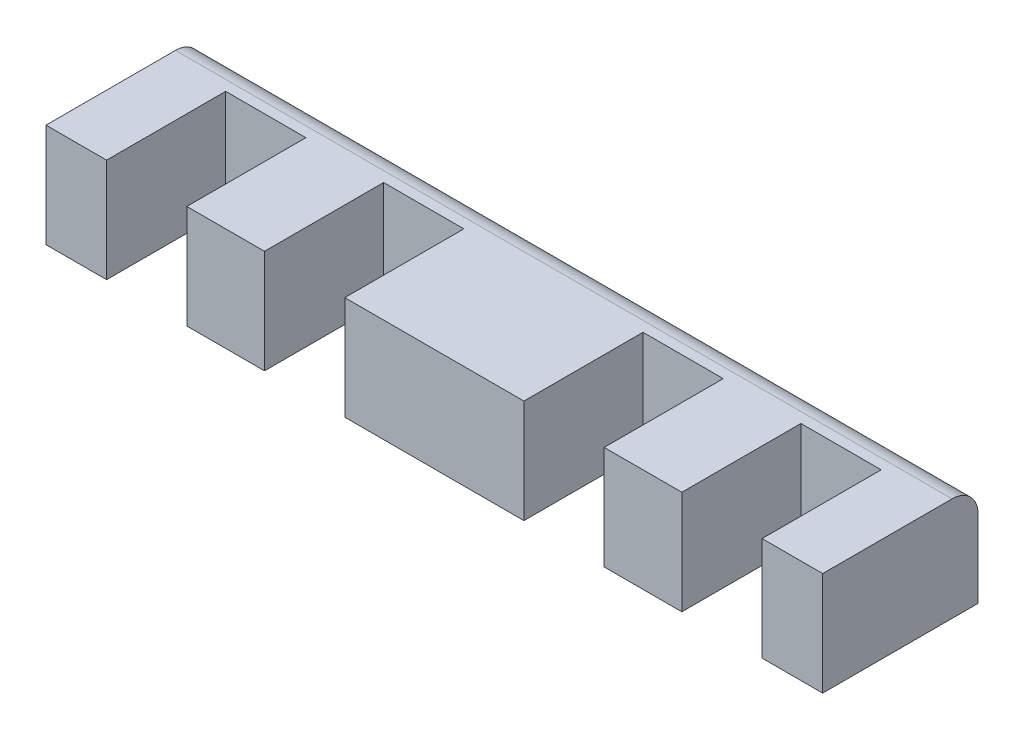
from build123d import *

# Parameters (mm, degrees)
BOSS_EXTRUDE1_DEPTH = 20
FILLET1_R           = 5


with BuildPart() as part:
    # Sketch1 → Boss-Extrude1 (new body)
    with BuildSketch(Plane(origin=(0, 0, 0), x_dir=(1, 0, 0), z_dir=(0, 1, 0))):
        Polygon((-75, 15), (-75, -15), (-63.3, -15), (-63.3, 8), (-47.8, 8), (-47.8, -15), (-32.8, -15), (-32.8, 8), (-17.3, 8), (-17.3, -15), (17.3, -15), (17.3, 8), (32.8, 8), (32.8, -15), (47.8, -15), (47.8, 8), (63.3, 8), (63.3, -15), (75, -15), (75, 15), align=None)
    extrude(amount=BOSS_EXTRUDE1_DEPTH)

    # Fillet1
    fillet1_edges = [part.edges().sort_by_distance(p)[0] for p in [
        (0, 20, -15),
    ]]
    fillet(fillet1_edges, radius=FILLET1_R)


solid = part.part
